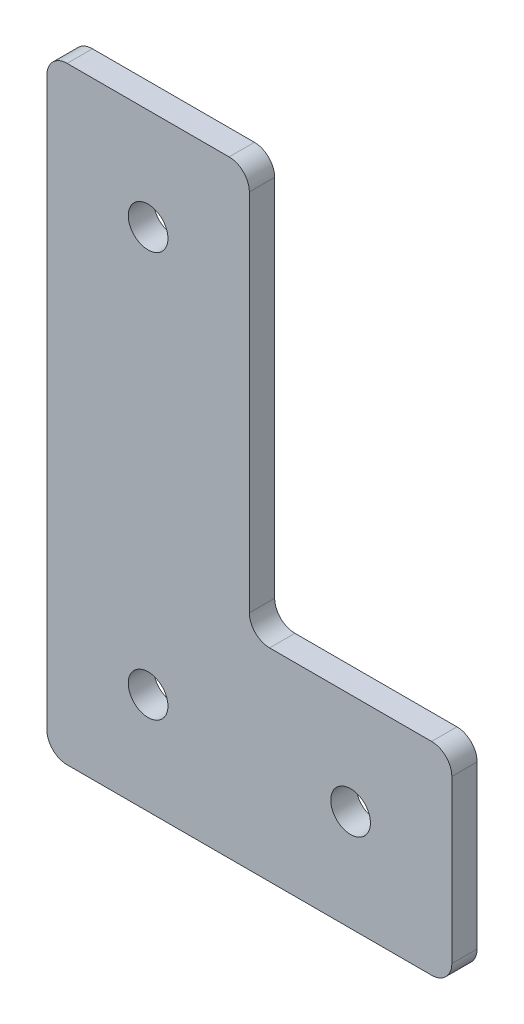
from build123d import *

# Parameters (mm, degrees)
SKETCH1_R           = 2.4892
BOSS_EXTRUDE1_DEPTH = 3.175


with BuildPart() as part:
    # Sketch1 → Boss-Extrude1 (new body)
    with BuildSketch(Plane.XY):
        with BuildLine():
            Line((0, 73.66), (0, 2.54))
            ThreePointArc((0, 2.54), (0.743948776, 0.743948776), (2.54, 0))
            Line((2.54, 0), (48.26, 0))
            ThreePointArc((48.26, 0), (50.056051224, 0.743948776), (50.8, 2.54))
            Line((50.8, 2.54), (50.8, 22.86))
            ThreePointArc((50.8, 22.86), (50.056051224, 24.656051224), (48.26, 25.4))
            Line((48.26, 25.4), (27.94, 25.4))
            ThreePointArc((27.94, 25.4), (26.143948776, 26.143948776), (25.4, 27.94))
            Line((25.4, 27.94), (25.4, 73.66))
            ThreePointArc((25.4, 73.66), (24.656051224, 75.456051224), (22.86, 76.2))
            Line((22.86, 76.2), (2.54, 76.2))
            ThreePointArc((2.54, 76.2), (0.743948776, 75.456051224), (0, 73.66))
        make_face()
        with Locations((12.7, 63.5)):
            Circle(SKETCH1_R, mode=Mode.SUBTRACT)
        with Locations((12.7, 12.7)):
            Circle(SKETCH1_R, mode=Mode.SUBTRACT)
        with Locations((38.1, 12.7)):
            Circle(SKETCH1_R, mode=Mode.SUBTRACT)
    extrude(amount=BOSS_EXTRUDE1_DEPTH)


solid = part.part
